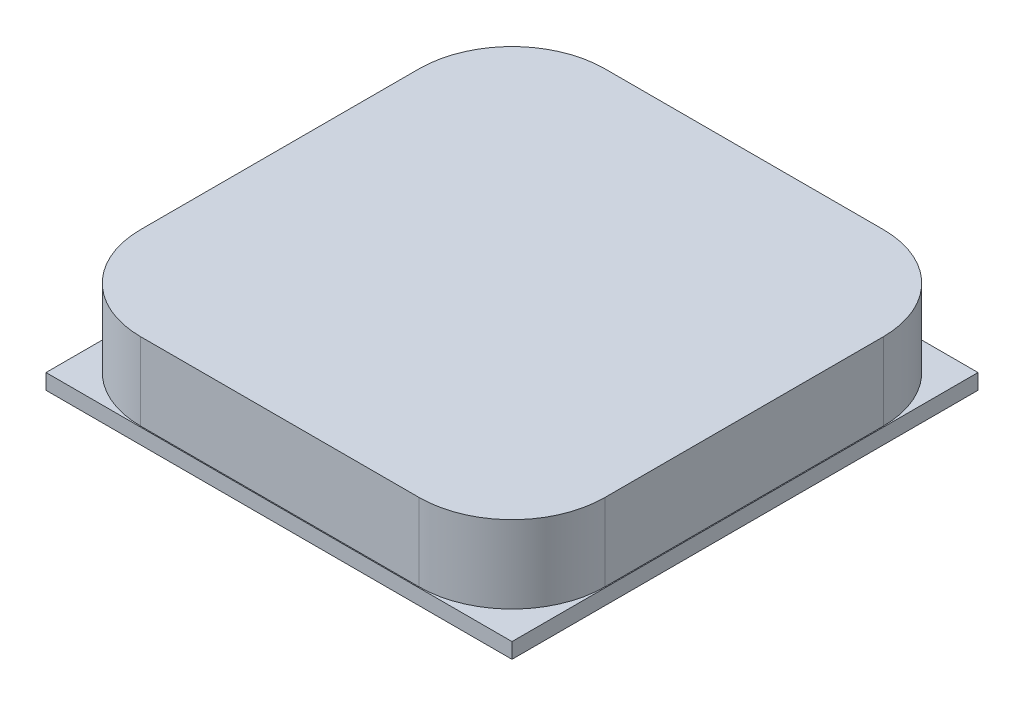
from build123d import *

# Parameters (mm, degrees)
SKETCH1_W           = 25.1
SKETCH1_H           = 25.1
BOSS_EXTRUDE1_DEPTH = 0.83
SKETCH2_W           = 25
SKETCH2_H           = 25
BOSS_EXTRUDE2_DEPTH = 5
FILLET1_R           = 5
BOSS_EXTRUDE3_DEPTH = 2.4
CHAMFER1_SIZE       = 0.5


with BuildPart() as part:
    # Sketch1 → Boss-Extrude1 (new body)
    with BuildSketch(Plane(origin=(0, 0, 0), x_dir=(1, 0, 0), z_dir=(0, 1, 0))):
        Rectangle(SKETCH1_W, SKETCH1_H)
    extrude(amount=BOSS_EXTRUDE1_DEPTH)

    # Sketch2 → Boss-Extrude2 (add)
    with BuildSketch(Plane(origin=(0, 0, 0), x_dir=(1, 0, 0), z_dir=(0, 1, 0))):
        Rectangle(SKETCH2_W, SKETCH2_H)
    extrude(amount=BOSS_EXTRUDE2_DEPTH)

    # Fillet1
    fillet1_edges = [part.edges().sort_by_distance(p)[0] for p in [
        (12.5, 2.915, 12.5),
        (12.5, 2.915, -12.5),
        (-12.5, 2.915, -12.5),
        (-12.5, 2.915, 12.5),
    ]]
    fillet(fillet1_edges, radius=FILLET1_R)

    # Sketch3 → Boss-Extrude3 (add)
    with BuildSketch(Plane(origin=(0, 0, 0), x_dir=(1, 0, 0), z_dir=(0, 1, 0))):
        Polygon((8, 7), (-8, 7), (-8, -7), (8, -7), (8, -1.5), (5, -1.5), (5, 1.5), (8, 1.5), align=None)
    extrude(amount=-BOSS_EXTRUDE3_DEPTH)

    # Chamfer1
    chamfer1_edges = [part.edges().sort_by_distance(p)[0] for p in [
        (0, 0, -7),
        (0, 0, 7),
    ]]
    chamfer(chamfer1_edges, length=CHAMFER1_SIZE)


solid = part.part
